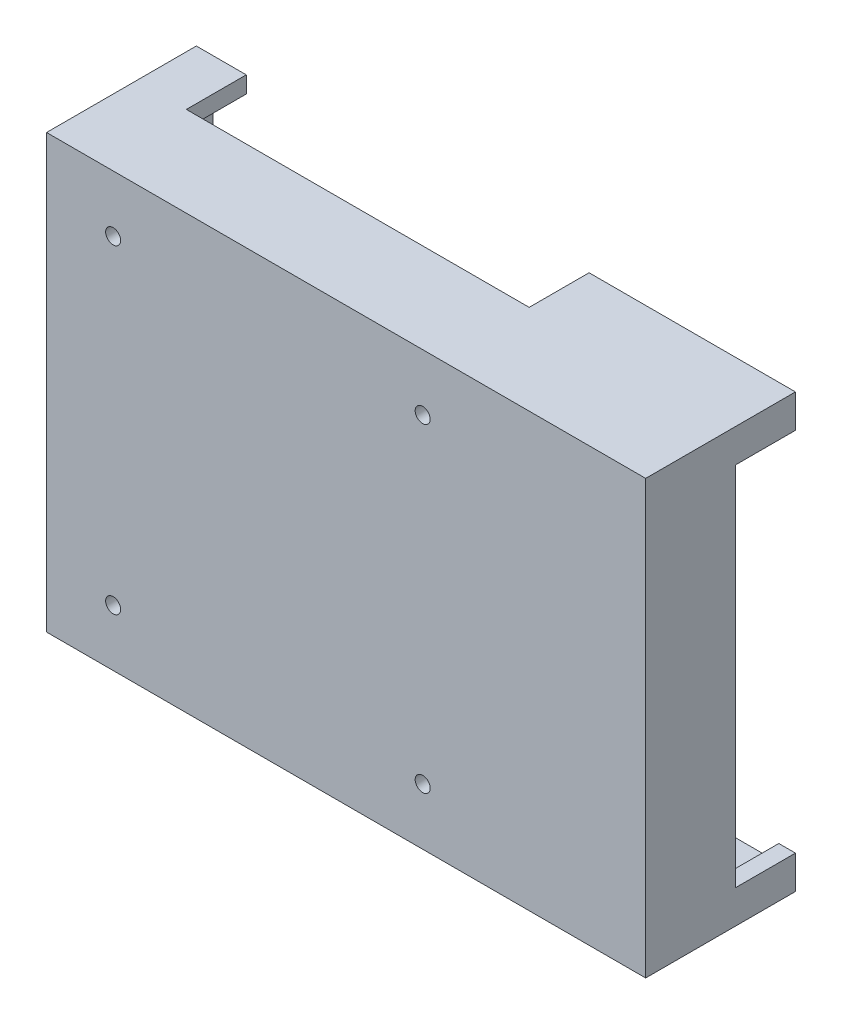
from build123d import *

# Parameters (mm, degrees)
SKETCH1_W            = 180
SKETCH1_H            = 130
BOSS_EXTRUDE1_DEPTH  = 45
SKETCH3_W            = 170
SKETCH3_H            = 120
CUT_EXTRUDE1_DEPTH   = 40
M4_CLEARANCE_HOLE1_D = 4.5
CUT_EXTRUDE2_REACH   = 182
SKETCH7_W            = 18
SKETCH7_H            = 110
SKETCH8_W            = 103
SKETCH8_H            = 18
CUT_EXTRUDE3_DEPTH   = 130


with BuildPart() as part:
    # Sketch1 → Boss-Extrude1 (new body)
    with BuildSketch(Plane.XY):
        Rectangle(SKETCH1_W, SKETCH1_H)
    extrude(amount=BOSS_EXTRUDE1_DEPTH)

    # Sketch3 → Cut-Extrude1 (cut)
    with BuildSketch(Plane.XY):
        Rectangle(SKETCH3_W, SKETCH3_H)
    extrude(amount=CUT_EXTRUDE1_DEPTH, mode=Mode.SUBTRACT)

    # M4 Clearance Hole1 (through all)
    with Locations(Plane(origin=(0, 0, 40), x_dir=(-1, 0, 0), z_dir=(0, 0, -1))):
        with Locations((-23, -48), (70, -48), (70, 48), (-23, 48)):
            Hole(M4_CLEARANCE_HOLE1_D / 2)

    # Sketch7 → Cut-Extrude2 (cut, up to next)
    with BuildSketch(Plane(origin=(90, 0, 0), x_dir=(0, 0, -1), z_dir=(1, 0, 0)), mode=Mode.PRIVATE) as cut_extrude2_sk1:
        with Locations((-9, 0)):
            Rectangle(SKETCH7_W, SKETCH7_H)
    cut_extrude2_tool1 = extrude(cut_extrude2_sk1.sketch, amount=-CUT_EXTRUDE2_REACH, mode=Mode.PRIVATE) & part.part
    add(cut_extrude2_tool1.solids().sort_by_distance((90, 0, 9))[0], mode=Mode.SUBTRACT)

    # Sketch8 → Cut-Extrude3 (cut)
    with BuildSketch(Plane.XZ.offset(65)):
        with Locations((-23.5, 9)):
            Rectangle(SKETCH8_W, SKETCH8_H)
    extrude(amount=-CUT_EXTRUDE3_DEPTH, mode=Mode.SUBTRACT)


solid = part.part
